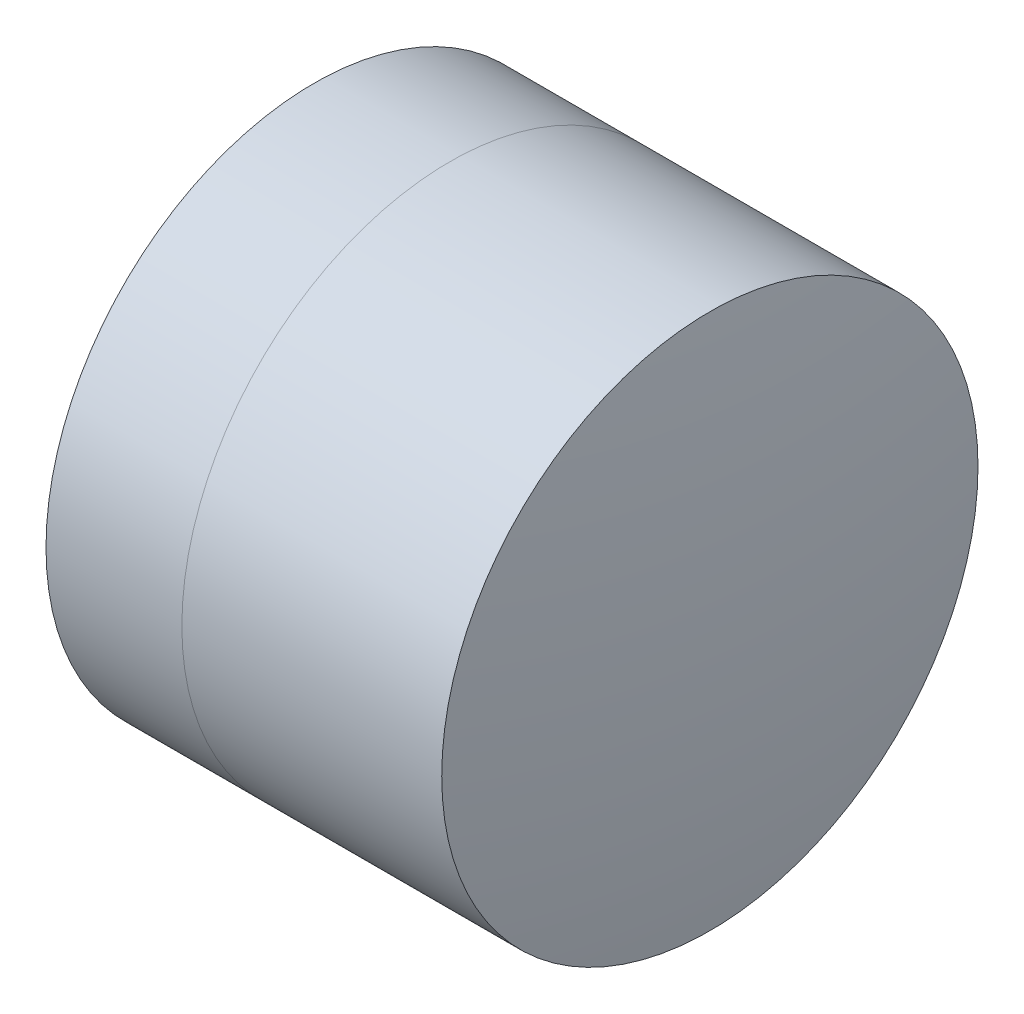
from build123d import *


with BuildPart() as part:
    # 草图1 one side → 旋转1 (revolve)
    with BuildSketch(Plane(origin=(0, 0, 0), x_dir=(1, 0, 0), z_dir=(0, 1, 0)), mode=Mode.PRIVATE) as revolve_1_sk:
        with BuildLine():
            ThreePointArc((1.904885755, 2.5), (1.437268823, 1.288673453), (1.278214333, 0))
            Line((1.278214333, 0), (4.078214333, 0))
            ThreePointArc((4.078214333, 0), (3.844545677, 1.329667055), (3.171540242, 2.5))
            Line((3.171540242, 2.5), (1.904885755, 2.5))
        make_face()
    revolve(revolve_1_sk.sketch.rotate(Axis((-0.816062176, 0, 0), (1, 0, 0)), 180), axis=Axis((-0.816062176, 0, 0), (1, 0, 0)))  # turned: the seam where the file's is


with BuildPart() as body_2:
    # 草图2 one side → 旋转3 (revolve)
    with BuildSketch(Plane(origin=(0, 0, 0), x_dir=(1, 0, 0), z_dir=(0, 1, 0)), mode=Mode.PRIVATE) as revolve_3_sk:
        with BuildLine():
            Line((5.594478696, 2.5), (3.171540242, 2.5))
            ThreePointArc((3.171540242, 2.5), (3.844545677, 1.329667055), (4.078214333, 0))
            Line((4.078214333, 0), (5.778214333, 0))
            ThreePointArc((5.778214333, 0), (5.732218564, 1.253371332), (5.594478696, 2.5))
        make_face()
    revolve(revolve_3_sk.sketch.rotate(Axis((-0.551919993, 0, 0), (1, 0, 0)), 180), axis=Axis((-0.551919993, 0, 0), (1, 0, 0)))  # turned: the seam where the file's is


solid = Compound([part.part, body_2.part])
